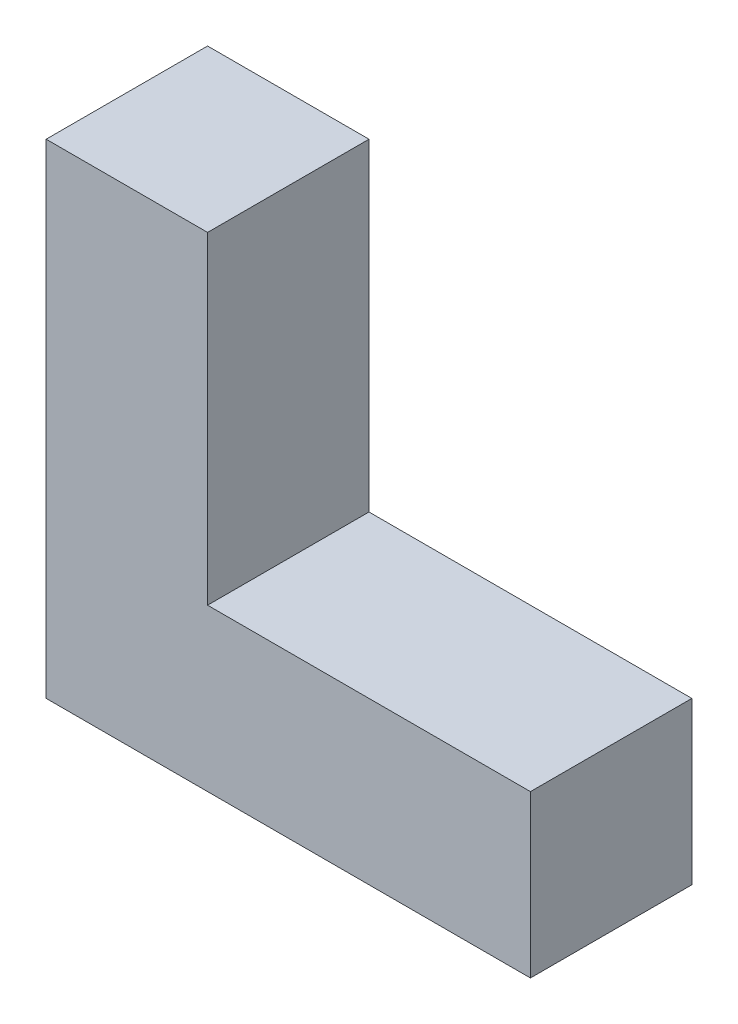
from build123d import *

# Parameters (mm, degrees)
BOSS_EXTRUDE1_DEPTH = 25.4


with BuildPart() as part:
    # Sketch1 → Boss-Extrude1 (new body)
    with BuildSketch(Plane.XY):
        Polygon((76.2, 0), (76.2, 25.4), (25.4, 25.4), (25.4, 76.2), (0, 76.2), (0, 0), align=None)
    extrude(amount=BOSS_EXTRUDE1_DEPTH)


solid = part.part
